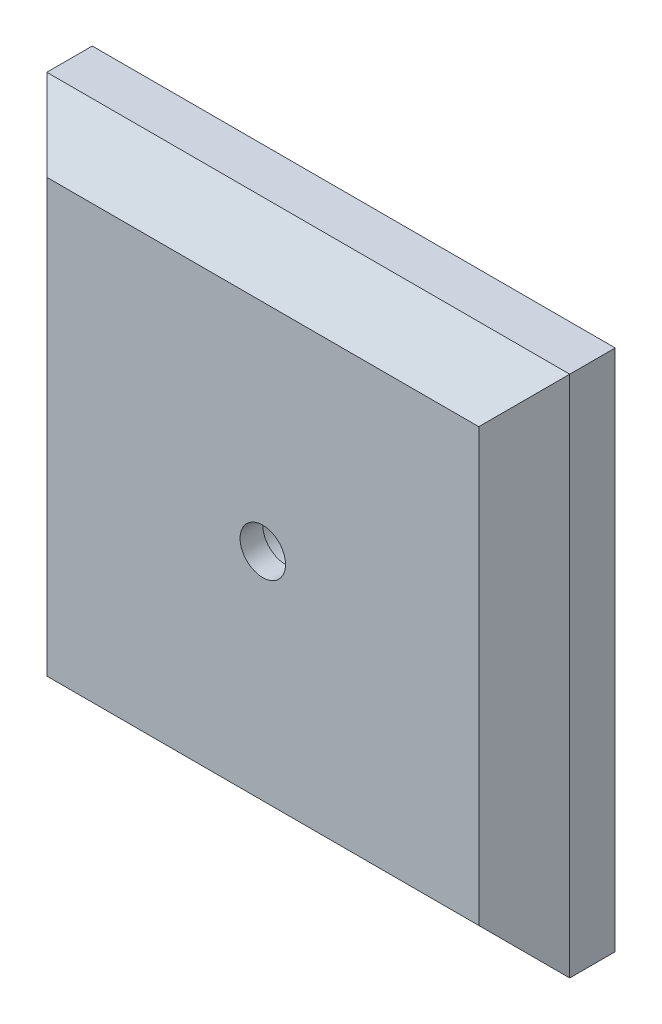
from build123d import *

# Parameters (mm, degrees)
SKETCH1_W           = 73.025
SKETCH1_H           = 73.025
BOSS_EXTRUDE1_DEPTH = 12.7
SKETCH2_R           = 3.175
CUT_EXTRUDE1_DEPTH  = 3.175
SKETCH3_R           = 4.7625
CUT_EXTRUDE2_DEPTH  = 10.525
CHAMFER1_SIZE       = 6.35


with BuildPart() as part:
    # Sketch1 → Boss-Extrude1 (new body)
    with BuildSketch(Plane.XY):
        Rectangle(SKETCH1_W, SKETCH1_H)
    extrude(amount=-BOSS_EXTRUDE1_DEPTH)

    # Sketch2 → Cut-Extrude1 (cut)
    with BuildSketch(Plane.XY):
        Circle(SKETCH2_R)
    extrude(amount=-CUT_EXTRUDE1_DEPTH, mode=Mode.SUBTRACT)

    # Sketch3 → Cut-Extrude2 (cut, through all)
    with BuildSketch(Plane.XY.offset(-3.175)):
        Circle(SKETCH3_R)
    extrude(amount=-CUT_EXTRUDE2_DEPTH, mode=Mode.SUBTRACT)

    # Chamfer1
    chamfer1_edges = [part.edges().sort_by_distance(p)[0] for p in [
        (0, 36.5125, 0),
        (36.5125, 0, 0),
        (0, -36.5125, 0),
        (-36.5125, 0, 0),
    ]]
    chamfer(chamfer1_edges, length=CHAMFER1_SIZE)


solid = part.part
